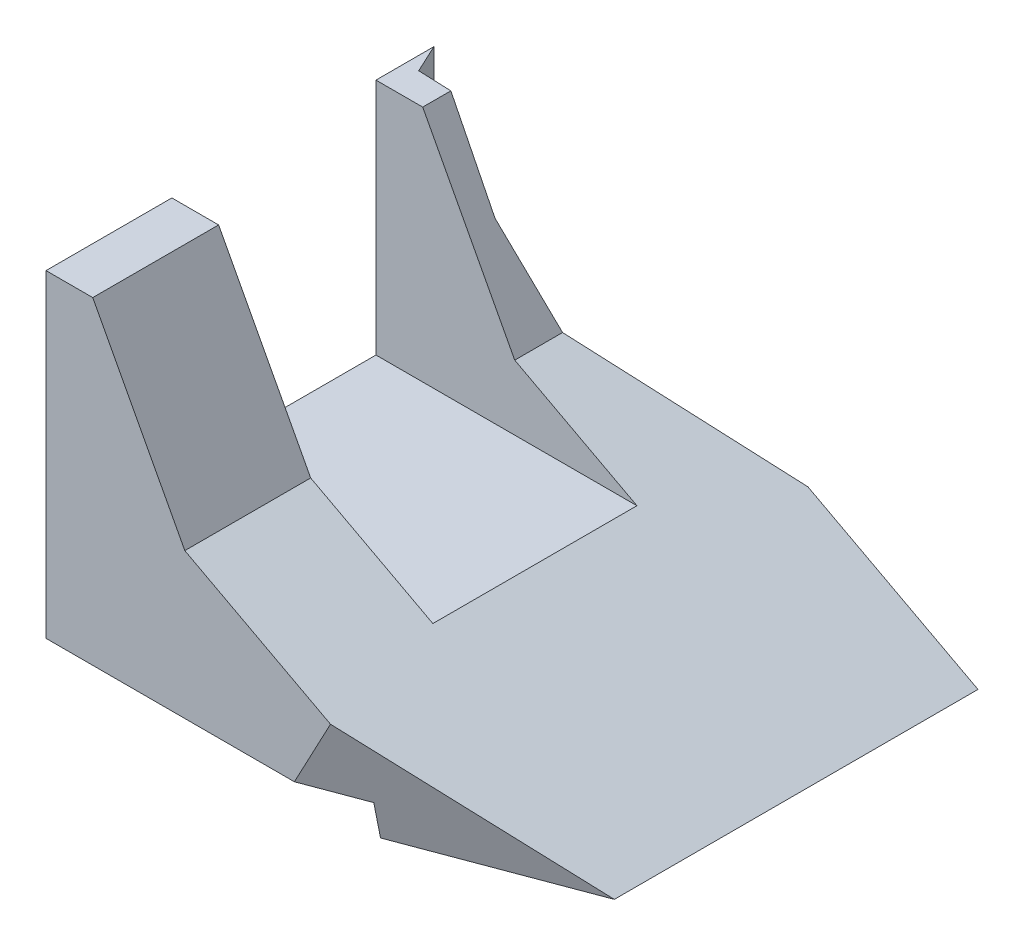
from build123d import *

# Parameters (mm, degrees)
CROQUIS1_W              = 67
CROQUIS1_H              = 51.82
SALIENTE_EXTRUIR1_DEPTH = 70
CORTAR_EXTRUIR1_REACH   = 69
CROQUIS4_W              = 60
CROQUIS4_H              = 30
CORTAR_EXTRUIR2_DEPTH   = 35
CORTAR_EXTRUIR3_REACH   = 69
CROQUIS5_W              = 45
CROQUIS5_H              = 5
CORTAR_EXTRUIR4_REACH   = 53.82
CORTAR_EXTRUIR5_REACH   = 53.82
CROQUIS11_R             = 1.589119195
CROQUIS11_R_2           = 1.628109744
CORTAR_EXTRUIR6_DEPTH   = 6
CROQUIS12_R             = 1.75
CORTAR_EXTRUIR7_DEPTH   = 7
CORTAR_EXTRUIR8_REACH   = 34.863


with BuildPart() as part:
    # Croquis1 → Saliente-Extruir1 (new body)
    with BuildSketch(Plane(origin=(0, 0, 0), x_dir=(0, 0, -1), z_dir=(1, 0, 0))):
        with Locations((33.5, 25.91)):
            Rectangle(CROQUIS1_W, CROQUIS1_H)
    extrude(amount=SALIENTE_EXTRUIR1_DEPTH)

    # Croquis3 → Cortar-Extruir1 (cut, up to next)
    with BuildSketch(Plane.XY, mode=Mode.PRIVATE) as cortar_extruir1_sk1:
        Polygon((70, 0), (20.404370982, 26.370463718), (6.872612509, 51.82), (70, 51.82), align=None)
    cortar_extruir1_tool1 = extrude(cortar_extruir1_sk1.sketch, amount=-CORTAR_EXTRUIR1_REACH, mode=Mode.PRIVATE) & part.part
    add(cortar_extruir1_tool1.solids().sort_by_distance((45.373987, 32.707801, 0))[0], mode=Mode.SUBTRACT)

    # Croquis4 → Cortar-Extruir2 (cut)
    with BuildSketch(Plane(origin=(0, 51.82, 0), x_dir=(1, 0, 0), z_dir=(0, 1, 0))):
        with Locations((30, 33.5)):
            Rectangle(CROQUIS4_W, CROQUIS4_H)
    extrude(amount=-CORTAR_EXTRUIR2_DEPTH, mode=Mode.SUBTRACT)

    # Croquis5 → Cortar-Extruir3 (cut, up to next)
    with BuildSketch(Plane.XY, mode=Mode.PRIVATE) as cortar_extruir3_sk1:
        with Locations((22.5, 2.5)):
            Rectangle(CROQUIS5_W, CROQUIS5_H)
    cortar_extruir3_tool1 = extrude(cortar_extruir3_sk1.sketch, amount=-CORTAR_EXTRUIR3_REACH, mode=Mode.PRIVATE) & part.part
    add(cortar_extruir3_tool1.solids().sort_by_distance((22.5, 2.5, 0))[0], mode=Mode.SUBTRACT)

    # Croquis6 → Cortar-Extruir4 (cut, up to next)
    with BuildSketch(Plane(origin=(0, 51.82, 0), x_dir=(1, 0, 0), z_dir=(0, 1, 0)), mode=Mode.PRIVATE) as cortar_extruir4_sk1:
        Polygon((4.922856145, 67), (0, 64.334655313), (0, 67), align=None)
    cortar_extruir4_tool1 = extrude(cortar_extruir4_sk1.sketch, amount=-CORTAR_EXTRUIR4_REACH, mode=Mode.PRIVATE) & part.part
    add(cortar_extruir4_tool1.solids().sort_by_distance((1.640952, 51.82, -66.111552))[0], mode=Mode.SUBTRACT)

    # Croquis9 → Cortar-Extruir5 (cut, up to next)
    with BuildSketch(Plane(origin=(0, 51.82, 0), x_dir=(1, 0, 0), z_dir=(0, 1, 0)), mode=Mode.PRIVATE) as cortar_extruir5_sk1:
        Polygon((45, 67), (13.626202653, 52.370158031), (1.954435626, 52.832439456), (-4.658833913, 67.014641749), align=None)
    cortar_extruir5_tool1 = extrude(cortar_extruir5_sk1.sketch, amount=-CORTAR_EXTRUIR5_REACH, mode=Mode.PRIVATE) & part.part
    add(cortar_extruir5_tool1.solids().sort_by_distance((15.368059, 51.82, -61.265598))[0], mode=Mode.SUBTRACT)

    # Croquis11 → Cortar-Extruir6 (cut)
    with BuildSketch(Plane.ZY):
        with Locations((-14.75, 23.32)):
            Circle(CROQUIS11_R)
        with Locations((-51.75, 23.32)):
            Circle(CROQUIS11_R_2)
    extrude(amount=-CORTAR_EXTRUIR6_DEPTH, mode=Mode.SUBTRACT)

    # Croquis12 → Cortar-Extruir7 (cut)
    with BuildSketch(Plane.XZ.offset(-5)):
        with Locations((10, -9)):
            Circle(CROQUIS12_R)
        with Locations((35, -9)):
            Circle(CROQUIS12_R)
        with Locations((10, -47.51378034)):
            Circle(CROQUIS12_R)
        with Locations((35, -29)):
            Circle(CROQUIS12_R)
        with Locations((10, -29)):
            Circle(CROQUIS12_R)
        with Locations((35, -54)):
            Circle(CROQUIS12_R)
    extrude(amount=-CORTAR_EXTRUIR7_DEPTH, mode=Mode.SUBTRACT)

    # Croquis14 → Cortar-Extruir8 (cut, up to next)
    with BuildSketch(Plane(origin=(15.428248379, 29.016315039, 0), x_dir=(0.882947593, -0.469471563, 0), z_dir=(0.469471563, 0.882947593, 0)), mode=Mode.PRIVATE) as cortar_extruir8_sk1:
        Polygon((25.978815345, -1.66), (66.698815345, -1.66), (66.698815345, 15.62), align=None)
    cortar_extruir8_tool1 = extrude(cortar_extruir8_sk1.sketch, amount=-CORTAR_EXTRUIR8_REACH, mode=Mode.PRIVATE) & part.part
    add(cortar_extruir8_tool1.solids().sort_by_distance((62.335265, 4.075412, -4.1))[0], mode=Mode.SUBTRACT)


solid = part.part
